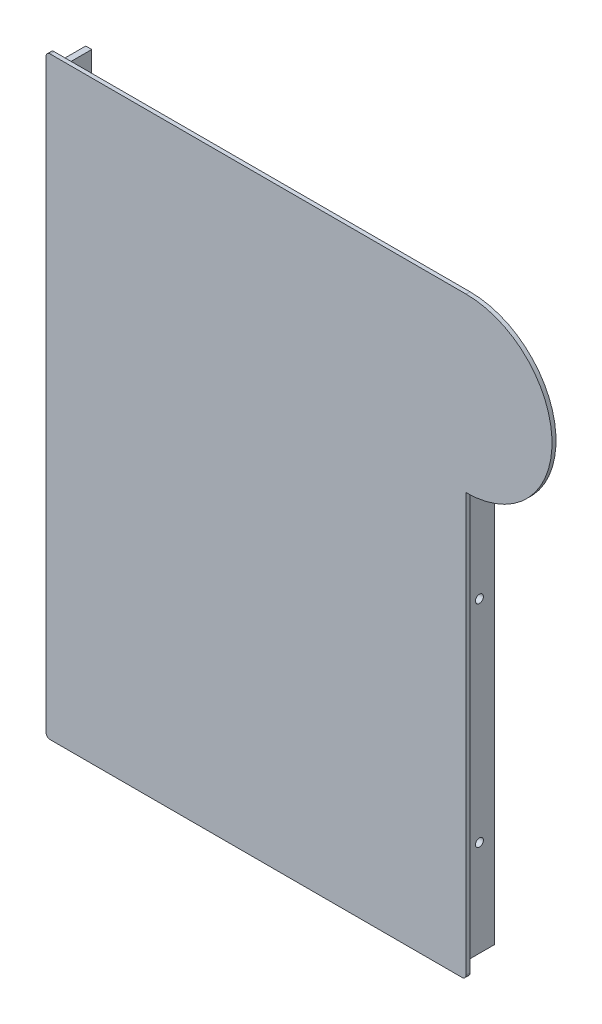
from build123d import *

# Parameters (mm, degrees)
EXTRUDE_1_DEPTH     = 2
EXTRUDE_1_2_DEPTH   = 15
SKETCH_4_R          = 2
CUT_EXTRUDE_1_DEPTH = 15
SKETCH_5_R          = 2
CUT_EXTRUDE_2_DEPTH = 283


with BuildPart() as part:
    # 草图1 → Extrude 1 (new body)
    with BuildSketch(Plane.XY):
        with BuildLine():
            Line((0, 53.35), (-208, 53.35))
            ThreePointArc((-208, 53.35), (-209.414213562, 52.764213562), (-210, 51.35))
            Line((-210, 51.35), (-210, -241.65))
            ThreePointArc((-210, -241.65), (-209.414213562, -243.064213562), (-208, -243.65))
            Line((-208, -243.65), (-2, -243.65))
            ThreePointArc((-2, -243.65), (-0.585786438, -243.064213562), (0, -241.65))
            Line((0, -241.65), (0, -32.65))
            ThreePointArc((0, -32.65), (43, 10.35), (0, 53.35))
        make_face()
    extrude(amount=EXTRUDE_1_DEPTH)

    # 草图3 → Extrude 1 2 (add)
    with BuildSketch(Plane(origin=(0, 0, 0), x_dir=(-1, 0, 0), z_dir=(0, 0, -1))):
        Polygon((207.2, 48.687657947), (207.2, -238.454577256), (205.130446753, -240.85), (5.682615129, -240.85), (2.8, -238.359531245), (2.8, -37.127932812), (5.8, -37.127932812), (5.8, -236.986839537), (6.799072726, -237.85), (203.757755045, -237.85), (204.2, -237.338119658), (204.2, 48.687657947), align=None)
    extrude(amount=EXTRUDE_1_2_DEPTH)

    # 草图4 → 切除-拉伸1 (cut)
    with BuildSketch(Plane.XZ.offset(240.85)):
        with Locations((-167.807888651, -7.5)):
            Circle(SKETCH_4_R)
        with Locations((-42.192111349, -7.5)):
            Circle(SKETCH_4_R)
    extrude(amount=-CUT_EXTRUDE_1_DEPTH, mode=Mode.SUBTRACT)

    # 草图5 → 切除-拉伸2 (cut)
    with BuildSketch(Plane.ZY.offset(207.2)):
        with Locations((-7.5, -190.350496004)):
            Circle(SKETCH_5_R)
        with Locations((-7.5, -84.801056957)):
            Circle(SKETCH_5_R)
    extrude(amount=-CUT_EXTRUDE_2_DEPTH, mode=Mode.SUBTRACT)


solid = part.part
